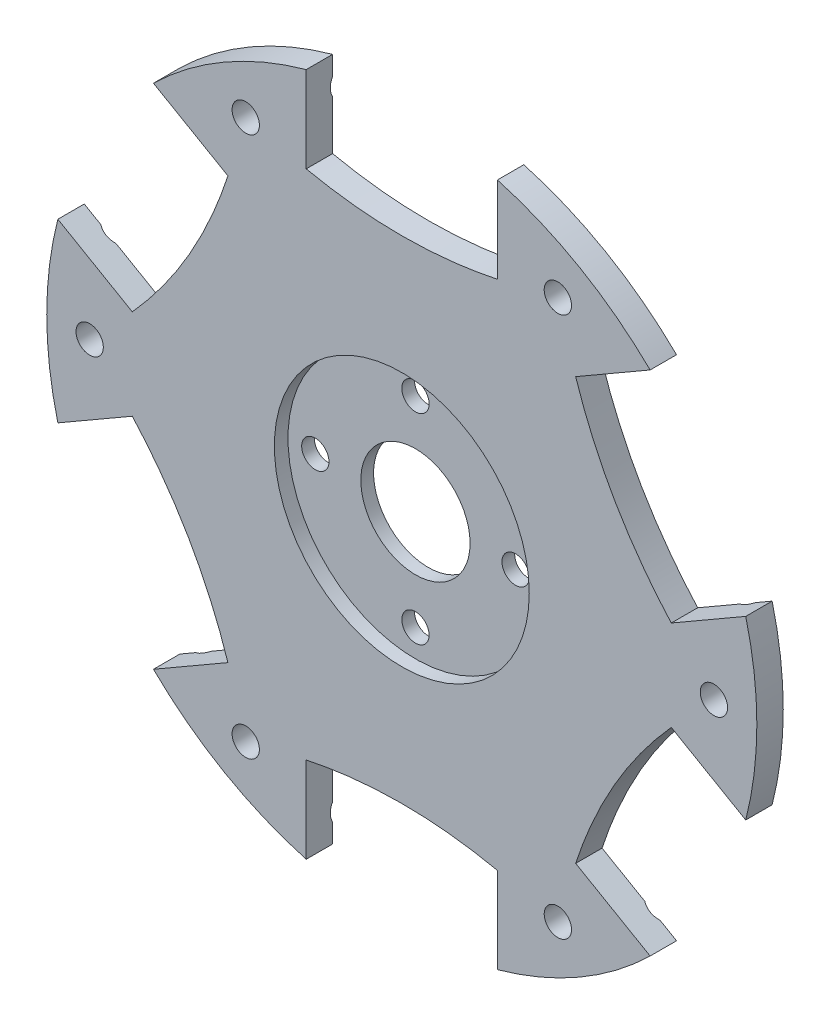
from build123d import *

# Parameters (mm, degrees)
CROQUIS2_R              = 1.5
CROQUIS2_R_2            = 6
SALIENTE_EXTRUIR2_DEPTH = 2.9
CROQUIS4_R              = 2
CORTAR_EXTRUIR1_DEPTH   = 12.5
MATRIZC1_COUNT          = 6
CROQUIS5_R              = 1.5
CORTAR_EXTRUIR2_DEPTH   = 10
CROQUIS6_R              = 14
CORTAR_EXTRUIR3_DEPTH   = 1.5


with BuildPart() as part:
    # Croquis2 → Saliente-Extruir2 (new body)
    with BuildSketch(Plane.XY):
        with BuildLine():
            Line((-10.5, 28.115792599), (-10.5, 37.559952077))
            ThreePointArc((-10.5, 37.559952077), (-19.5, 33.774990748), (-27.277872663, 27.873242778))
            Line((-27.277872663, 27.873242778), (-19.098990638, 23.151163039))
            add(Edge.make_bspline(
                [(-29.598990638, 4.96462956), (-22.416381166, 12.9421037), (-19.098990638, 23.151163039)],
                knots=[0, 0, 0, 1, 1, 1], degree=2))
            Line((-29.598990638, 4.96462956), (-37.777872663, 9.686709299))
            ThreePointArc((-37.777872663, 9.686709299), (-39, 0), (-37.777872663, -9.686709299))
            Line((-37.777872663, -9.686709299), (-29.598990638, -4.96462956))
            add(Edge.make_bspline(
                [(-19.098990638, -23.151163039), (-22.416381166, -12.9421037), (-29.598990638, -4.96462956)],
                knots=[0, 0, 0, 1, 1, 1], degree=2))
            Line((-19.098990638, -23.151163039), (-27.277872663, -27.873242778))
            ThreePointArc((-27.277872663, -27.873242778), (-19.5, -33.774990748), (-10.5, -37.559952077))
            Line((-10.5, -37.559952077), (-10.5, -28.115792599))
            add(Edge.make_bspline(
                [(10.5, -28.115792599), (0, -25.884207401), (-10.5, -28.115792599)],
                knots=[0, 0, 0, 1, 1, 1], degree=2))
            Line((10.5, -28.115792599), (10.5, -37.559952077))
            ThreePointArc((10.5, -37.559952077), (19.5, -33.774990748), (27.277872663, -27.873242778))
            Line((27.277872663, -27.873242778), (19.098990638, -23.151163039))
            add(Edge.make_bspline(
                [(29.598990638, -4.96462956), (22.416381166, -12.9421037), (19.098990638, -23.151163039)],
                knots=[0, 0, 0, 1, 1, 1], degree=2))
            Line((29.598990638, -4.96462956), (37.777872663, -9.686709299))
            ThreePointArc((37.777872663, -9.686709299), (38.693261906, -4.88175), (39, 0))
            ThreePointArc((39, 0), (38.693261906, 4.88175), (37.777872663, 9.686709299))
            Line((37.777872663, 9.686709299), (29.598990638, 4.96462956))
            add(Edge.make_bspline(
                [(19.098990638, 23.151163039), (22.416381166, 12.9421037), (29.598990638, 4.96462956)],
                knots=[0, 0, 0, 1, 1, 1], degree=2))
            Line((19.098990638, 23.151163039), (27.277872663, 27.873242778))
            ThreePointArc((27.277872663, 27.873242778), (19.5, 33.774990748), (10.5, 37.559952077))
            Line((10.5, 37.559952077), (10.5, 28.115792599))
            add(Edge.make_bspline(
                [(-10.5, 28.115792599), (0, 25.884207401), (10.5, 28.115792599)],
                knots=[0, 0, 0, 1, 1, 1], degree=2))
        make_face()
        with Locations((-17.142037335, -29.69087961)):
            Circle(CROQUIS2_R, mode=Mode.SUBTRACT)
        with Locations((-34.28407467, 0)):
            Circle(CROQUIS2_R, mode=Mode.SUBTRACT)
        with Locations((17.142037335, -29.69087961)):
            Circle(CROQUIS2_R, mode=Mode.SUBTRACT)
        with Locations((-17.142037335, 29.69087961)):
            Circle(CROQUIS2_R, mode=Mode.SUBTRACT)
        Circle(CROQUIS2_R_2, mode=Mode.SUBTRACT)
        with Locations((34.28407467, 0)):
            Circle(CROQUIS2_R, mode=Mode.SUBTRACT)
        with Locations((17.142037335, 29.69087961)):
            Circle(CROQUIS2_R, mode=Mode.SUBTRACT)
    extrude(amount=SALIENTE_EXTRUIR2_DEPTH)

    # Croquis4 → Cortar-Extruir1 (cut, symmetric)
    with BuildSketch(Plane(origin=(0, 0, 0), x_dir=(0, 0, -1), z_dir=(1, 0, 0))):
        with Locations((1.75, 34.5)):
            Circle(CROQUIS4_R)
    cortar_extruir1 = extrude(amount=CORTAR_EXTRUIR1_DEPTH, both=True, mode=Mode.SUBTRACT)

    # MatrizC1: Cortar-Extruir1 ×6 about axis
    matrizc1_axis = Axis((0, 0, 0), (0, 0, 1))
    for i in range(1, MATRIZC1_COUNT):
        add(cortar_extruir1.rotate(matrizc1_axis, i * 360 / MATRIZC1_COUNT), mode=Mode.SUBTRACT)

    # Croquis5 → Cortar-Extruir2 (cut)
    with BuildSketch(Plane.XY.offset(2.9)):
        with Locations((11, 0)):
            Circle(CROQUIS5_R)
        with Locations((0, -11)):
            Circle(CROQUIS5_R)
        with Locations((-11, 0)):
            Circle(CROQUIS5_R)
        with Locations((0, 11)):
            Circle(CROQUIS5_R)
    extrude(amount=-CORTAR_EXTRUIR2_DEPTH, mode=Mode.SUBTRACT)

    # Croquis6 → Cortar-Extruir3 (cut)
    with BuildSketch(Plane.XY.offset(2.9)):
        Circle(CROQUIS6_R)
    extrude(amount=-CORTAR_EXTRUIR3_DEPTH, mode=Mode.SUBTRACT)


solid = part.part
